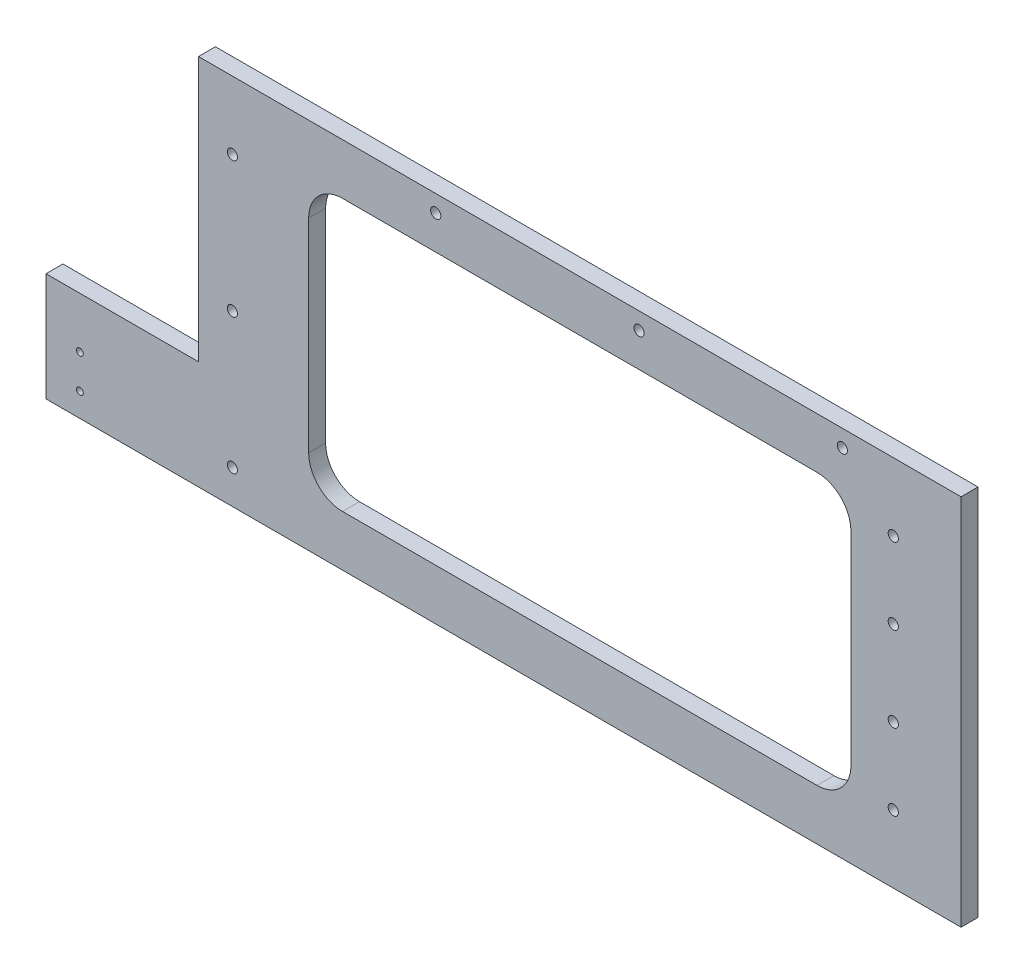
from build123d import *

# Parameters (mm, degrees)
SKETCH1_W           = 225
SKETCH1_H           = 110
BOSS_EXTRUDE1_DEPTH = 5
SKETCH2_W           = 5
SKETCH2_H           = 32
BOSS_EXTRUDE2_DEPTH = 45
SKETCH3_R           = 1.5
CUT_EXTRUDE1_DEPTH  = 6
SKETCH4_R           = 1.5
CUT_EXTRUDE2_DEPTH  = 6
SKETCH5_R           = 1
CUT_EXTRUDE3_DEPTH  = 6
SKETCH6_W           = 160
SKETCH6_H           = 80
CUT_EXTRUDE4_DEPTH  = 6
FILLET1_R           = 10


with BuildPart() as part:
    # Sketch1 → Boss-Extrude1 (new body)
    with BuildSketch(Plane.XY):
        Rectangle(SKETCH1_W, SKETCH1_H)
    extrude(amount=BOSS_EXTRUDE1_DEPTH)

    # Sketch2 → Boss-Extrude2 (add)
    with BuildSketch(Plane.ZY.offset(112.5)):
        with Locations((2.5, -39)):
            Rectangle(SKETCH2_W, SKETCH2_H)
    extrude(amount=BOSS_EXTRUDE2_DEPTH)

    # Sketch3 → Cut-Extrude1 (cut, through all)
    with BuildSketch(Plane.XY.offset(5)):
        with Locations((92.5, 35)):
            Circle(SKETCH3_R)
        with Locations((92.5, 12.5)):
            Circle(SKETCH3_R)
        with Locations((92.5, -12.5)):
            Circle(SKETCH3_R)
        with Locations((92.5, -35)):
            Circle(SKETCH3_R)
    extrude(amount=-CUT_EXTRUDE1_DEPTH, mode=Mode.SUBTRACT)

    # Sketch4 → Cut-Extrude2 (cut, through all)
    with BuildSketch(Plane.XY.offset(5)):
        with Locations((-42.5, 50)):
            Circle(SKETCH4_R)
        with Locations((-102.5, 35)):
            Circle(SKETCH4_R)
        with Locations((17.5, 50)):
            Circle(SKETCH4_R)
        with Locations((77.5, 50)):
            Circle(SKETCH4_R)
        with Locations((-102.5, -5)):
            Circle(SKETCH4_R)
        with Locations((-102.5, -45)):
            Circle(SKETCH4_R)
    extrude(amount=-CUT_EXTRUDE2_DEPTH, mode=Mode.SUBTRACT)

    # Sketch5 → Cut-Extrude3 (cut, through all)
    with BuildSketch(Plane.XY.offset(5)):
        with Locations((-147.5, -38)):
            Circle(SKETCH5_R)
        with Locations((-147.5, -48)):
            Circle(SKETCH5_R)
    extrude(amount=-CUT_EXTRUDE3_DEPTH, mode=Mode.SUBTRACT)

    # Sketch6 → Cut-Extrude4 (cut, through all)
    with BuildSketch(Plane.XY.offset(5)):
        Rectangle(SKETCH6_W, SKETCH6_H)
    extrude(amount=-CUT_EXTRUDE4_DEPTH, mode=Mode.SUBTRACT)

    # Fillet1
    fillet1_edges = [part.edges().sort_by_distance(p)[0] for p in [
        (-80, -40, 2.5),
        (-80, 40, 2.5),
        (80, 40, 2.5),
        (80, -40, 2.5),
    ]]
    fillet(fillet1_edges, radius=FILLET1_R)


solid = part.part
